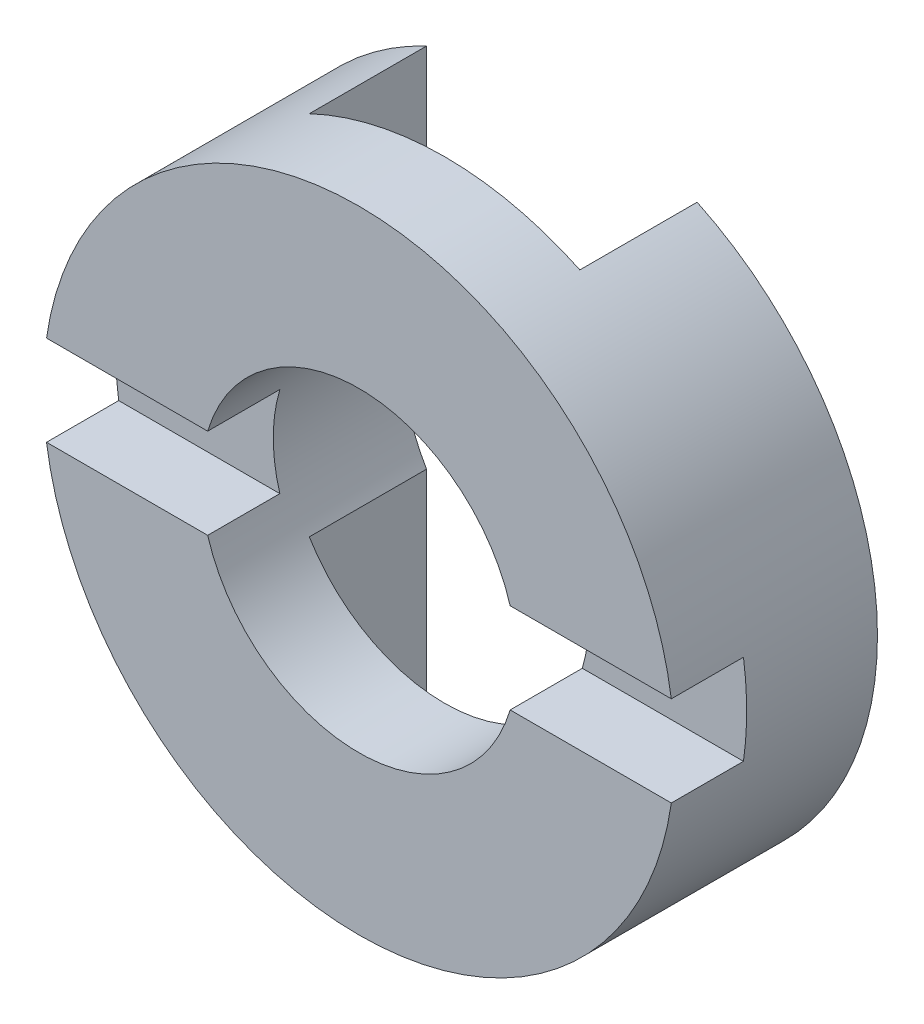
from build123d import *

# Parameters (mm, degrees)
SKETCH_1_R               = 7
SKETCH_1_R_2             = 3.5
EXTRUDE_1_DEPTH          = 4.5
SKETCH_2_W               = 6
SKETCH_2_H               = 2.6
CUT_EXTRUDE_1_DEPTH      = 8
CUT_EXTRUDE_1_DEPTH_BACK = 8
SKETCH_3_W               = 1.6
SKETCH_3_H               = 2
CUT_EXTRUDE_2_DEPTH      = 8
CUT_EXTRUDE_2_DEPTH_BACK = 8


with BuildPart() as part:
    # Эскиз1 → Бобышка-Вытянуть1 (new body)
    with BuildSketch(Plane.XY):
        Circle(SKETCH_1_R)
        Circle(SKETCH_1_R_2, mode=Mode.SUBTRACT)
    extrude(amount=EXTRUDE_1_DEPTH)

    # Эскиз2 → Вырез-Вытянуть1 (cut, two sides)
    with BuildSketch(Plane(origin=(0, 0, 0), x_dir=(1, 0, 0), z_dir=(0, 1, 0))) as cut_extrude_1_sk:
        with Locations((0, -1.3)):
            Rectangle(SKETCH_2_W, SKETCH_2_H)
    extrude(amount=CUT_EXTRUDE_1_DEPTH, mode=Mode.SUBTRACT)
    extrude(cut_extrude_1_sk.sketch, amount=-CUT_EXTRUDE_1_DEPTH_BACK, mode=Mode.SUBTRACT)

    # Эскиз3 → Вырез-Вытянуть2 (cut, two sides)
    with BuildSketch(Plane(origin=(0, 0, 0), x_dir=(0, 0, -1), z_dir=(1, 0, 0))) as cut_extrude_2_sk:
        with Locations((-3.7, 0)):
            Rectangle(SKETCH_3_W, SKETCH_3_H)
    extrude(amount=CUT_EXTRUDE_2_DEPTH, mode=Mode.SUBTRACT)
    extrude(cut_extrude_2_sk.sketch, amount=-CUT_EXTRUDE_2_DEPTH_BACK, mode=Mode.SUBTRACT)


solid = part.part
